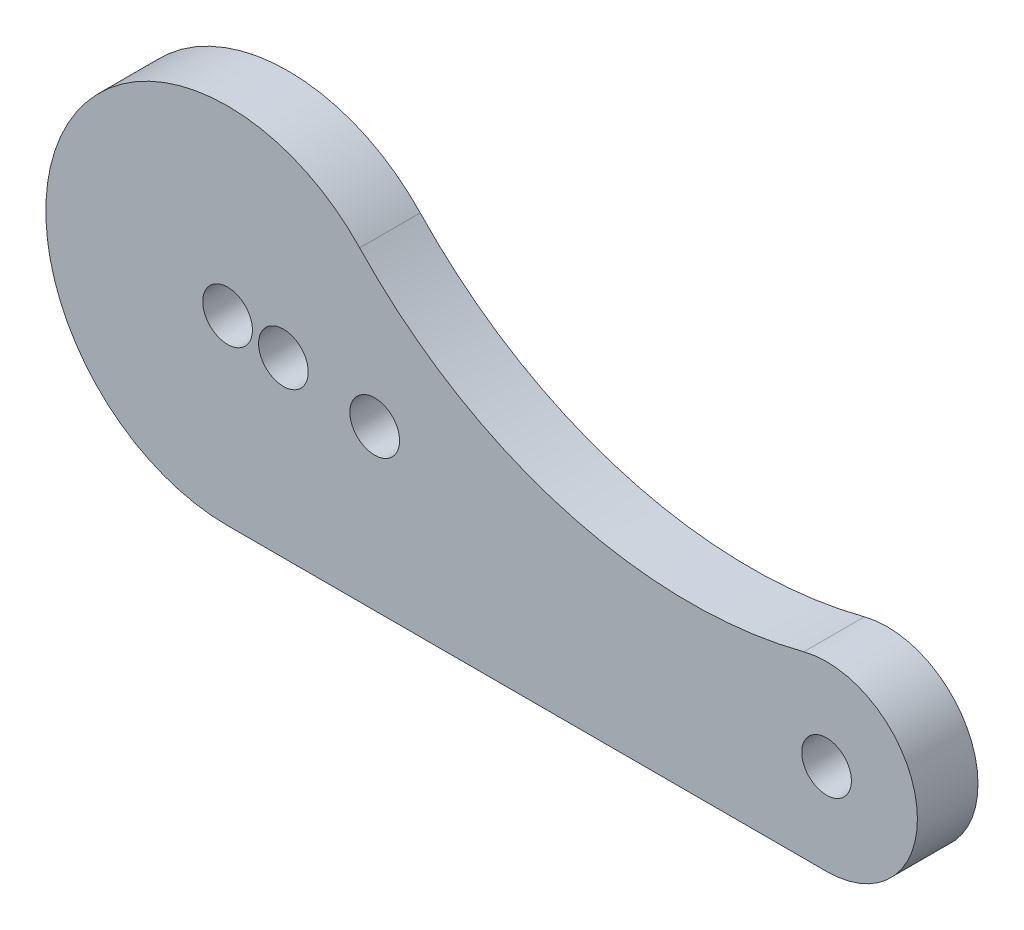
from build123d import *

# Parameters (mm, degrees)
SCHIZZO1_R                   = 2.05
ESTRUSIONE_ESTRUSIONE1_DEPTH = 5
CUT_EXTRUDE1_REACH           = 7
SKETCH1_R                    = 2.05


with BuildPart() as part:
    # Schizzo1 → Estrusione-Estrusione1 (new body)
    with BuildSketch(Plane.XY):
        with BuildLine():
            Line((0, -15), (49.434299833, -15))
            ThreePointArc((49.434299833, -15), (56.874189574, -6.552349937), (47.554189972, -0.239477504))
            ThreePointArc((47.554189972, -0.239477504), (27.787162994, 0.02445935), (10.90104019, 10.30375285))
            ThreePointArc((10.90104019, 10.30375285), (-13.775998925, 5.934800218), (0, -15))
        make_face()
        Circle(SCHIZZO1_R, mode=Mode.SUBTRACT)
        with Locations((49.434299833, -7.5)):
            Circle(SCHIZZO1_R, mode=Mode.SUBTRACT)
    extrude(amount=ESTRUSIONE_ESTRUSIONE1_DEPTH)

    # Sketch1 → Cut-Extrude1 (cut, up to next)
    with BuildSketch(Plane.XY.offset(5), mode=Mode.PRIVATE) as cut_extrude1_sk1:
        with Locations((4.608166562, -0.699135)):
            Circle(SKETCH1_R)
    cut_extrude1_tool1 = extrude(cut_extrude1_sk1.sketch, amount=-CUT_EXTRUDE1_REACH, mode=Mode.PRIVATE) & part.part
    add(cut_extrude1_tool1.solids().sort_by_distance((4.608167, -0.699135, 5))[0], mode=Mode.SUBTRACT)
    # Sketch1 → Cut-Extrude1 (cut, up to next)
    with BuildSketch(Plane.XY.offset(5), mode=Mode.PRIVATE) as cut_extrude1_sk2:
        with Locations((12.141953856, -1.842135)):
            Circle(SKETCH1_R)
    cut_extrude1_tool2 = extrude(cut_extrude1_sk2.sketch, amount=-CUT_EXTRUDE1_REACH, mode=Mode.PRIVATE) & part.part
    add(cut_extrude1_tool2.solids().sort_by_distance((12.141954, -1.842135, 5))[0], mode=Mode.SUBTRACT)


solid = part.part
